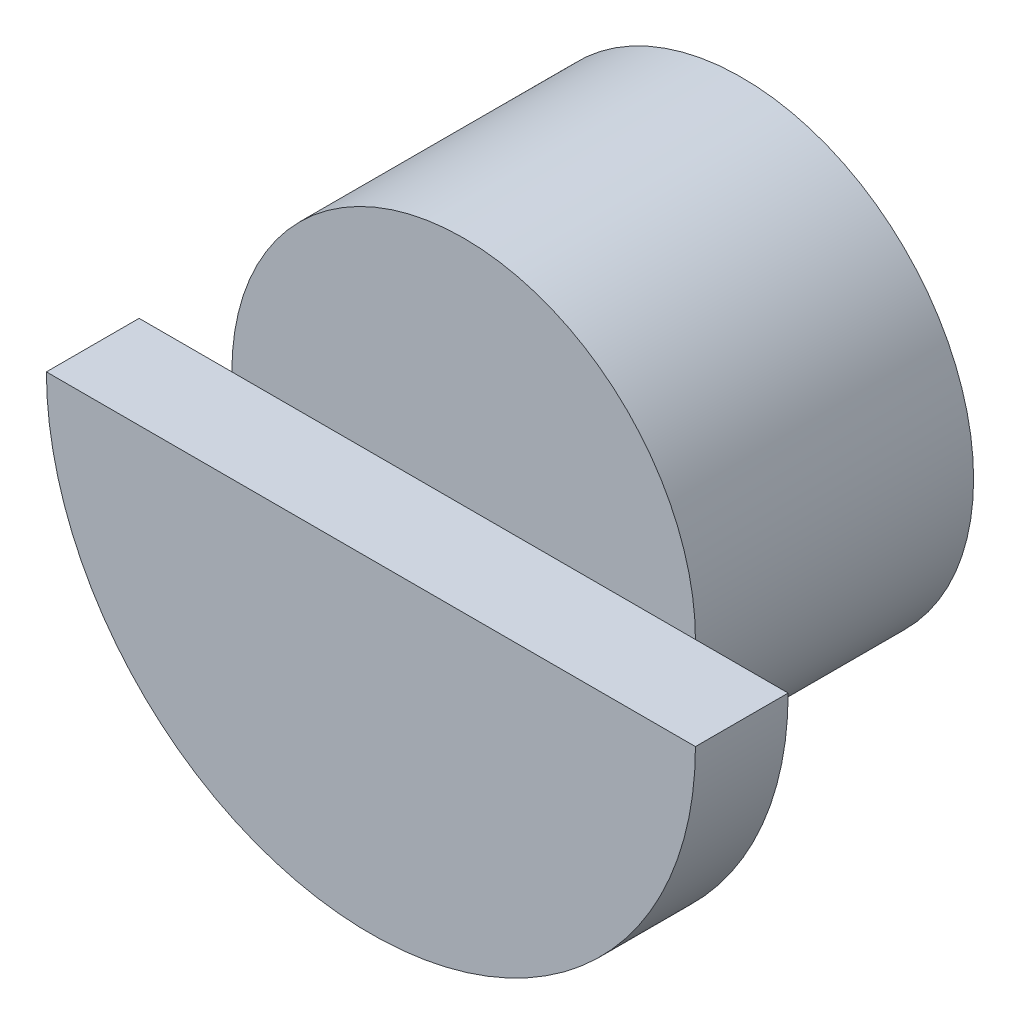
from build123d import *

# Parameters (mm, degrees)
SKETCH1_R           = 25
BOSS_EXTRUDE1_DEPTH = 30
BOSS_EXTRUDE2_DEPTH = 10


with BuildPart() as part:
    # Sketch1 → Boss-Extrude1 (new body)
    with BuildSketch(Plane.XY):
        Circle(SKETCH1_R)
    extrude(amount=BOSS_EXTRUDE1_DEPTH)

    # Sketch2 → Boss-Extrude2 (add)
    with BuildSketch(Plane.XY.offset(30)):
        with BuildLine():
            Line((-35, 0), (35, 0))
            ThreePointArc((35, 0), (0, -35), (-35, 0))
        make_face()
    extrude(amount=BOSS_EXTRUDE2_DEPTH)


solid = part.part
